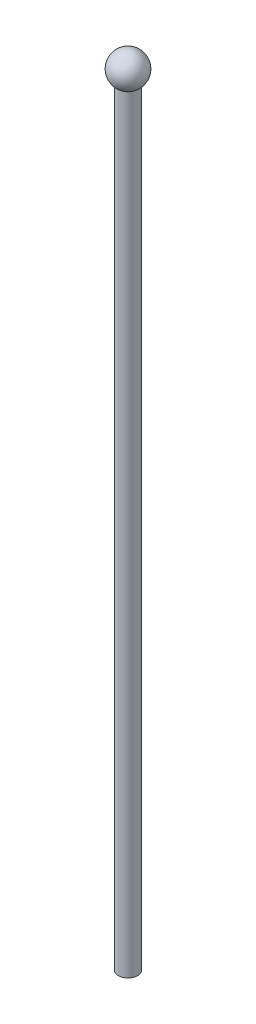
from build123d import *

# Parameters (mm, degrees)
SKETCH2_R           = 3.175
BOSS_EXTRUDE1_DEPTH = 254


with BuildPart() as part:
    # Sketch2 → Boss-Extrude1 (new body)
    with BuildSketch(Plane(origin=(0, 0, 0), x_dir=(1, 0, 0), z_dir=(0, 1, 0))):
        Circle(SKETCH2_R)
    extrude(amount=BOSS_EXTRUDE1_DEPTH)

    # Sketch3 → Revolve1 (revolve)
    with BuildSketch(Plane.XY):
        with BuildLine():
            Line((0, 252.959874363), (0, 263.691737843))
            ThreePointArc((0, 263.691737843), (-5.36593174, 258.325806103), (0, 252.959874363))
        make_face()
    revolve(axis=Axis((0, 252.959874363, 0), (0, 1, 0)))


solid = part.part
